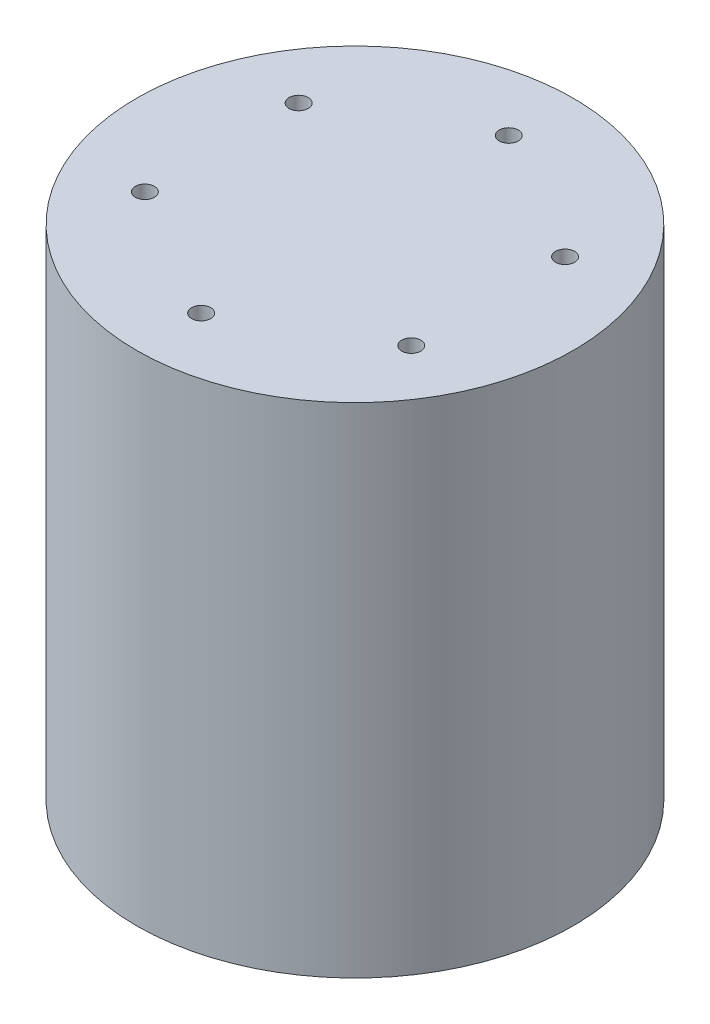
from build123d import *

# Parameters (mm, degrees)
CROQUIS1_R              = 35.5
SALIENTE_EXTRUIR1_DEPTH = 81
CROQUIS2_R              = 26
CROQUIS2_R_2            = 20
CORTAR_EXTRUIR1_DEPTH   = 7
CROQUIS3_R              = 1.6
CORTAR_EXTRUIR2_DEPTH   = 7
CROQUIS4_R              = 1.55
CORTAR_EXTRUIR3_DEPTH   = 7


with BuildPart() as part:
    # Croquis1 → Saliente-Extruir1 (new body)
    with BuildSketch(Plane(origin=(0, 0, 0), x_dir=(1, 0, 0), z_dir=(0, 1, 0))):
        Circle(CROQUIS1_R)
    extrude(amount=SALIENTE_EXTRUIR1_DEPTH)

    # Croquis2 → Cortar-Extruir1 (cut)
    with BuildSketch(Plane.XZ):
        Circle(CROQUIS2_R)
        Circle(CROQUIS2_R_2, mode=Mode.SUBTRACT)
    extrude(amount=-CORTAR_EXTRUIR1_DEPTH, mode=Mode.SUBTRACT)

    # Croquis3 → Cortar-Extruir2 (cut)
    with BuildSketch(Plane.XZ):
        with Locations((0, 15)):
            Circle(CROQUIS3_R)
        with Locations((14.265847744, 4.635254916)):
            Circle(CROQUIS3_R)
        with Locations((8.816778784, -12.135254916)):
            Circle(CROQUIS3_R)
        with Locations((-8.816778784, -12.135254916)):
            Circle(CROQUIS3_R)
        with Locations((-14.265847744, 4.635254916)):
            Circle(CROQUIS3_R)
    extrude(amount=-CORTAR_EXTRUIR2_DEPTH, mode=Mode.SUBTRACT)

    # Croquis4 → Cortar-Extruir3 (cut)
    with BuildSketch(Plane(origin=(0, 81, 0), x_dir=(1, 0, 0), z_dir=(0, 1, 0))):
        with Locations((0, 25)):
            Circle(CROQUIS4_R)
        with Locations((21.650635095, 12.5)):
            Circle(CROQUIS4_R)
        with Locations((21.650635095, -12.5)):
            Circle(CROQUIS4_R)
        with Locations((0, -25)):
            Circle(CROQUIS4_R)
        with Locations((-21.650635095, -12.5)):
            Circle(CROQUIS4_R)
        with Locations((-21.650635095, 12.5)):
            Circle(CROQUIS4_R)
    extrude(amount=-CORTAR_EXTRUIR3_DEPTH, mode=Mode.SUBTRACT)


solid = part.part
